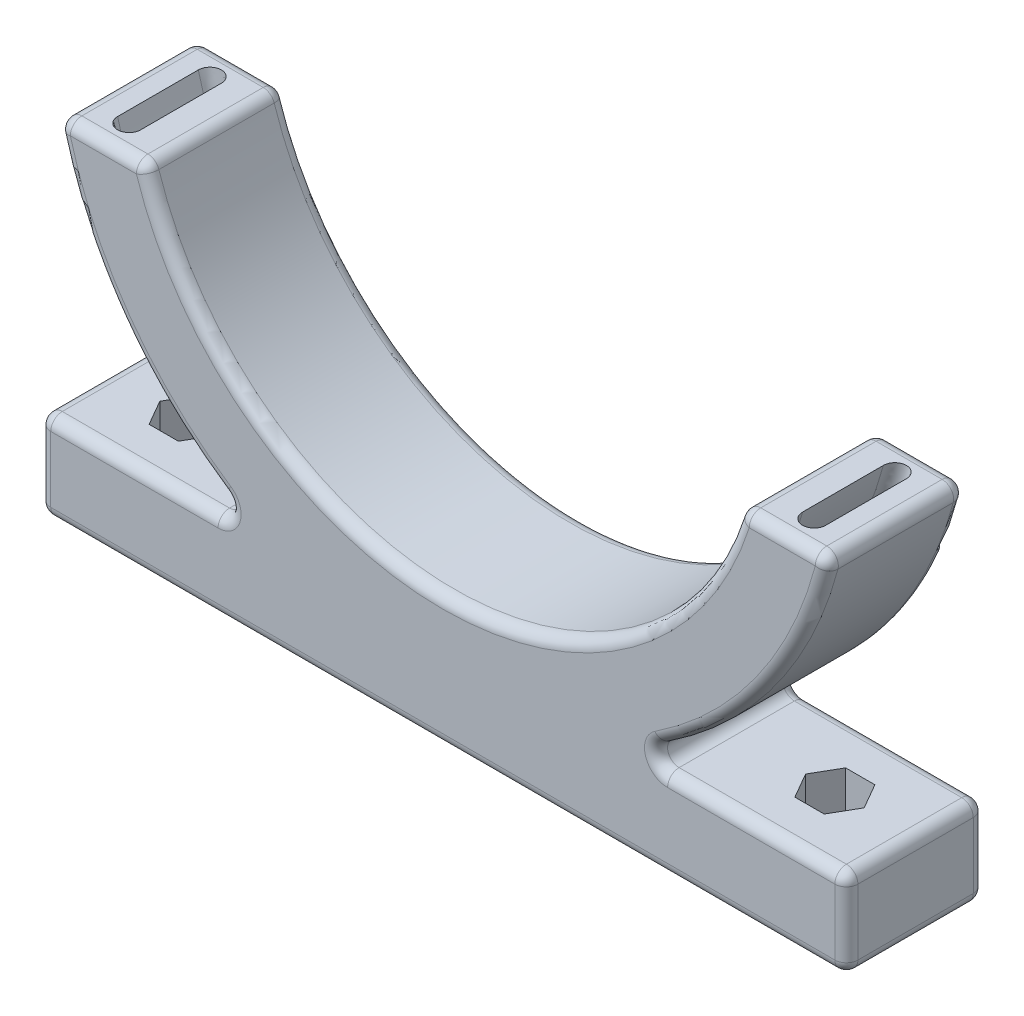
from build123d import *

# Parameters (mm, degrees)
BOSS_EXTRUDE1_DEPTH          = 15.24
FILLET1_R                    = 2.54
CUT_EXTRUDE1_DEPTH           = 10.16
H_0_266_DIAMETER_HOLE1_D     = 6.7564
H_0_266_DIAMETER_HOLE1_DEPTH = 19.558


with BuildPart() as part:
    # Sketch1 → Boss-Extrude1 (new body, symmetric)
    with BuildSketch(Plane.XY):
        with BuildLine():
            Line((-85.274045735, -19.05), (-65.616612043, -19.05))
            ThreePointArc((-65.616612043, -19.05), (0, -68.326), (65.616612043, -19.05))
            Line((65.616612043, -19.05), (85.274045735, -19.05))
            ThreePointArc((85.274045735, -19.05), (0, -87.376), (-85.274045735, -19.05))
        make_face()
        with BuildLine():
            ThreePointArc((40.165544525, -77.597), (0, -87.376), (-40.165544525, -77.597))
            Line((-40.165544525, -77.597), (-88.9, -77.597))
            Line((-88.9, -77.597), (-88.9, -97.155))
            Line((-88.9, -97.155), (88.9, -97.155))
            Line((88.9, -97.155), (88.9, -77.597))
            Line((88.9, -77.597), (40.165544525, -77.597))
        make_face()
    extrude(amount=BOSS_EXTRUDE1_DEPTH, both=True)

    # Cut-Sweep1: sweep along a path in Sketch4
    with BuildLine(Plane.XY) as cut_sweep1_path:
        CenterArc((0, 0), 77.978, 0, 360)
    # Sketch3 → Cut-Sweep1 (sweep, cut)
    with BuildSketch(Plane(origin=(0, -19.05, 0), x_dir=(1, 0, 0), z_dir=(0, 1, 0))):
        with BuildLine():
            Line((-77.985328889, -8.89), (-77.985328889, 8.89))
            ThreePointArc((-77.985328889, 8.89), (-75.445328889, 11.43), (-72.905328889, 8.89))
            Line((-72.905328889, 8.89), (-72.905328889, -8.89))
            ThreePointArc((-72.905328889, -8.89), (-75.445328889, -11.43), (-77.985328889, -8.89))
        make_face()
    sweep(path=cut_sweep1_path.line, mode=Mode.SUBTRACT)

    # Fillet1
    fillet1_edges = [part.edges().sort_by_distance(p)[0] for p in [
        (0, -68.326, -15.24),
        (75.445328889, -19.05, -15.24),
        (69.214958668, -53.327805811, -15.24),
        (64.532772263, -77.597, -15.24),
        (-64.532772263, -77.597, 15.24),
        (88.9, -87.376, -15.24),
        (0, -97.155, -15.24),
        (-88.9, -87.376, -15.24),
        (-64.532772263, -77.597, -15.24),
        (-69.214958668, -53.327805811, -15.24),
        (-75.445328889, -19.05, -15.24),
        (-88.9, -87.376, 15.24),
        (-65.616612043, -19.05, 0),
        (65.616612043, -19.05, 0),
        (85.274045735, -19.05, 0),
        (40.165544525, -77.597, 0),
        (88.9, -77.597, 0),
        (88.9, -97.155, 0),
        (-88.9, -97.155, 0),
        (-88.9, -77.597, 0),
        (-40.165544525, -77.597, 0),
        (-85.274045735, -19.05, 0),
        (0, -97.155, 15.24),
        (88.9, -87.376, 15.24),
        (64.532772263, -77.597, 15.24),
        (69.214958668, -53.327805811, 15.24),
        (75.445328889, -19.05, 15.24),
        (0, -68.326, 15.24),
        (-75.445328889, -19.05, 15.24),
        (-69.214958668, -53.327805811, 15.24),
    ]]
    fillet(fillet1_edges, radius=FILLET1_R)

    # Sketch5 → Cut-Extrude1 (cut)
    with BuildSketch(Plane(origin=(0, -77.597, 0), x_dir=(1, 0, 0), z_dir=(0, 1, 0))):
        Polygon((-67.893766696, 5.588), (-74.346233304, 5.588), (-77.572466608, 0), (-74.346233304, -5.588), (-67.893766696, -5.588), (-64.667533392, 0), align=None)
        Polygon((74.346233304, 5.588), (67.893766696, 5.588), (64.667533392, 0), (67.893766696, -5.588), (74.346233304, -5.588), (77.572466608, 0), align=None)
    extrude(amount=-CUT_EXTRUDE1_DEPTH, mode=Mode.SUBTRACT)

    # H (0.266) Diameter Hole1
    with Locations(Plane(origin=(-71.12, -77.597, 0), x_dir=(0, 0, 1), z_dir=(0, 1, 0))):
        with Locations((0, 0), (0, 142.24)):
            Hole(H_0_266_DIAMETER_HOLE1_D / 2, depth=H_0_266_DIAMETER_HOLE1_DEPTH)


solid = part.part
